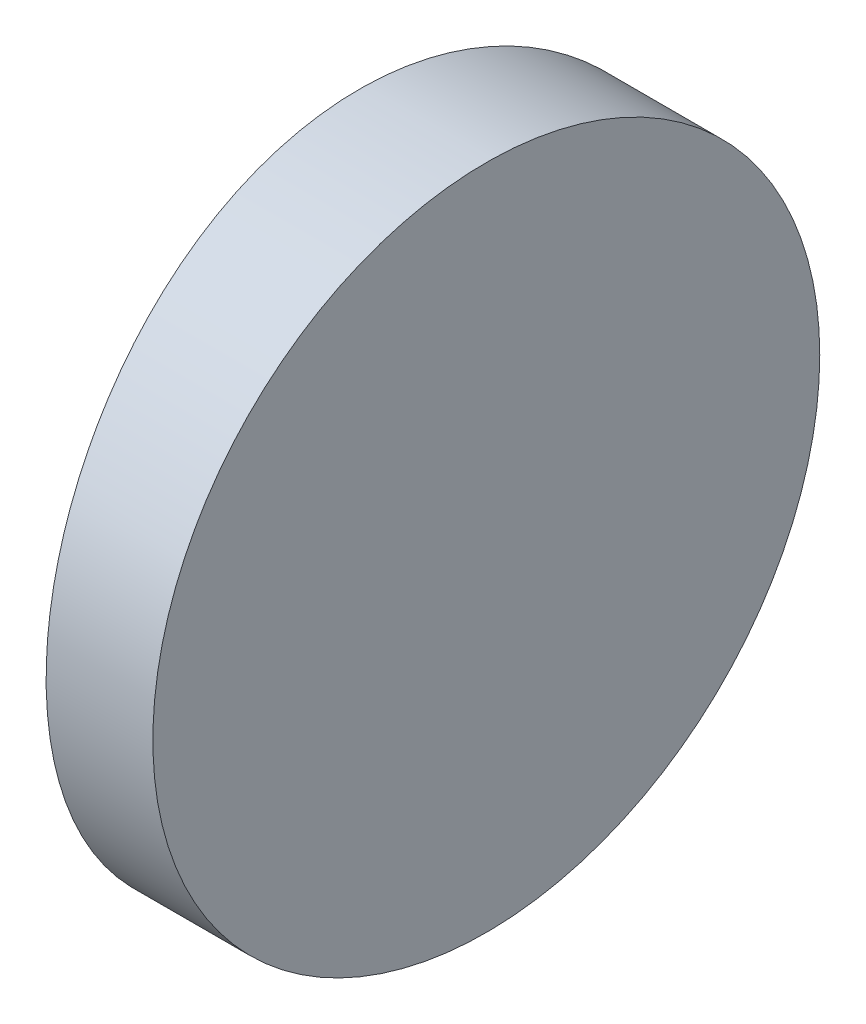
from build123d import *

# Parameters (mm, degrees)
EXTRUDE_1_DEPTH     = 12.5
CUT_EXTRUDE_8_DEPTH = 12.7


with BuildPart() as part:
    # 草图1 → 凸台-拉伸1 (new body)
    with BuildSketch(Plane(origin=(0, 0, 0), x_dir=(1, 0, 0), z_dir=(0, 1, 0))):
        with BuildLine():
            Line((-46.945476947, 6.25), (-44.944795665, 6.25))
            Line((-44.944795665, 6.25), (-44.944795665, -6.25))
            Line((-44.944795665, -6.25), (-46.945476947, -6.25))
            ThreePointArc((-46.945476947, -6.25), (-47.324795665, 0), (-46.945476947, 6.25))
        make_face()
    extrude(amount=EXTRUDE_1_DEPTH)

    # 草图2 → 切除-拉伸8 (cut)
    with BuildSketch(Plane(origin=(-44.944795665, 0, 0), x_dir=(0, 0, -1), z_dir=(1, 0, 0))):
        with BuildLine():
            Line((-6.25, 12.5), (-6.25, 6.25))
            ThreePointArc((-6.25, 6.25), (-4.419417382, 10.669417382), (0, 12.5))
            Line((0, 12.5), (-6.25, 12.5))
        make_face()
        with BuildLine():
            ThreePointArc((0, 12.5), (4.419417382, 10.669417382), (6.25, 6.25))
            Line((6.25, 6.25), (6.25, 12.5))
            Line((6.25, 12.5), (0, 12.5))
        make_face()
        with BuildLine():
            ThreePointArc((6.25, 6.25), (4.419417382, 1.830582618), (0, 0))
            Line((0, 0), (6.25, 0))
            Line((6.25, 0), (6.25, 6.25))
        make_face()
        with BuildLine():
            Line((-6.25, 6.25), (-6.25, 0))
            Line((-6.25, 0), (0, 0))
            ThreePointArc((0, 0), (-4.419417382, 1.830582618), (-6.25, 6.25))
        make_face()
    extrude(amount=-CUT_EXTRUDE_8_DEPTH, mode=Mode.SUBTRACT)


solid = part.part
